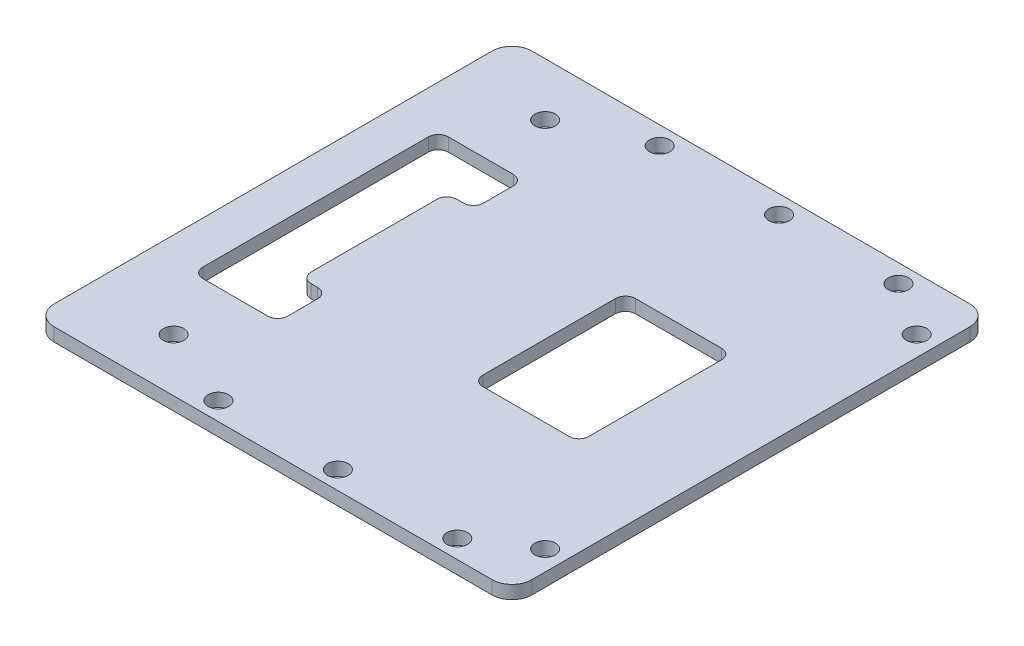
from build123d import *

# Parameters (mm, degrees)
SKETCH1_W           = 72
SKETCH1_H           = 72
SKETCH1_R           = 1.55
SKETCH1_W_2         = 16
SKETCH1_H_2         = 23
BOSS_EXTRUDE1_DEPTH = 2
FILLET1_R           = 1.5
SKETCH2_W           = 4
SKETCH2_H           = 22
BOSS_EXTRUDE2_DEPTH = 2
FILLET3_R           = 1.5
FILLET5_R           = 3


with BuildPart() as part:
    # Sketch1 → Boss-Extrude1 (new body)
    with BuildSketch(Plane(origin=(0, 0, 0), x_dir=(1, 0, 0), z_dir=(0, 1, 0))):
        with Locations((-5.976585554, 0)):
            Rectangle(SKETCH1_W, SKETCH1_H)
        with Locations((-28.976585554, -28)):
            Circle(SKETCH1_R, mode=Mode.SUBTRACT)
        with Locations((-16.976585554, -33.25)):
            Circle(SKETCH1_R, mode=Mode.SUBTRACT)
        Polygon((-22.776585554, 18.5), (-22.776585554, -18.5), (-27, -18.5), (-35.576585554, -18.5), (-35.576585554, 18.5), (-31.976585554, 18.5), align=None, mode=Mode.SUBTRACT)
        with Locations((1.023414446, -33.25)):
            Circle(SKETCH1_R, mode=Mode.SUBTRACT)
        with Locations((19.023414446, -33.25)):
            Circle(SKETCH1_R, mode=Mode.SUBTRACT)
        with Locations((27.023414446, -28)):
            Circle(SKETCH1_R, mode=Mode.SUBTRACT)
        with Locations((-28.976585554, 28)):
            Circle(SKETCH1_R, mode=Mode.SUBTRACT)
        with Locations((-16.976585554, 33.25)):
            Circle(SKETCH1_R, mode=Mode.SUBTRACT)
        with Locations((7.623414446, 0)):
            Rectangle(SKETCH1_W_2, SKETCH1_H_2, mode=Mode.SUBTRACT)
        with Locations((1.023414446, 33.25)):
            Circle(SKETCH1_R, mode=Mode.SUBTRACT)
        with Locations((19.023414446, 33.25)):
            Circle(SKETCH1_R, mode=Mode.SUBTRACT)
        with Locations((27.023414446, 28)):
            Circle(SKETCH1_R, mode=Mode.SUBTRACT)
    extrude(amount=BOSS_EXTRUDE1_DEPTH)

    # Fillet1
    fillet1_edges = [part.edges().sort_by_distance(p)[0] for p in [
        (-0.376585554, 1, 11.5),
        (15.623414446, 1, 11.5),
        (15.623414446, 1, -11.5),
        (-0.376585554, 1, -11.5),
        (-35.576585554, 1, 18.5),
        (-22.776585554, 1, 18.5),
        (-22.776585554, 1, -18.5),
        (-35.576585554, 1, -18.5),
    ]]
    fillet(fillet1_edges, radius=FILLET1_R)

    # Sketch2 → Boss-Extrude2 (add)
    with BuildSketch(Plane(origin=(0, 2, 0), x_dir=(1, 0, 0), z_dir=(0, 1, 0))):
        with Locations((-24.776585554, 0)):
            Rectangle(SKETCH2_W, SKETCH2_H)
    extrude(amount=-BOSS_EXTRUDE2_DEPTH)

    # Fillet3
    fillet3_edges = [part.edges().sort_by_distance(p)[0] for p in [
        (-26.776585554, 1, 11),
        (-26.776585554, 1, -11),
        (-22.776585554, 1, -11),
        (-22.776585554, 1, 11),
    ]]
    fillet(fillet3_edges, radius=FILLET3_R)

    # Fillet5
    fillet5_edges = [part.edges().sort_by_distance(p)[0] for p in [
        (-41.976585554, 1, -36),
        (30.023414446, 1, -36),
        (30.023414446, 1, 36),
        (-41.976585554, 1, 36),
    ]]
    fillet(fillet5_edges, radius=FILLET5_R)


solid = part.part
